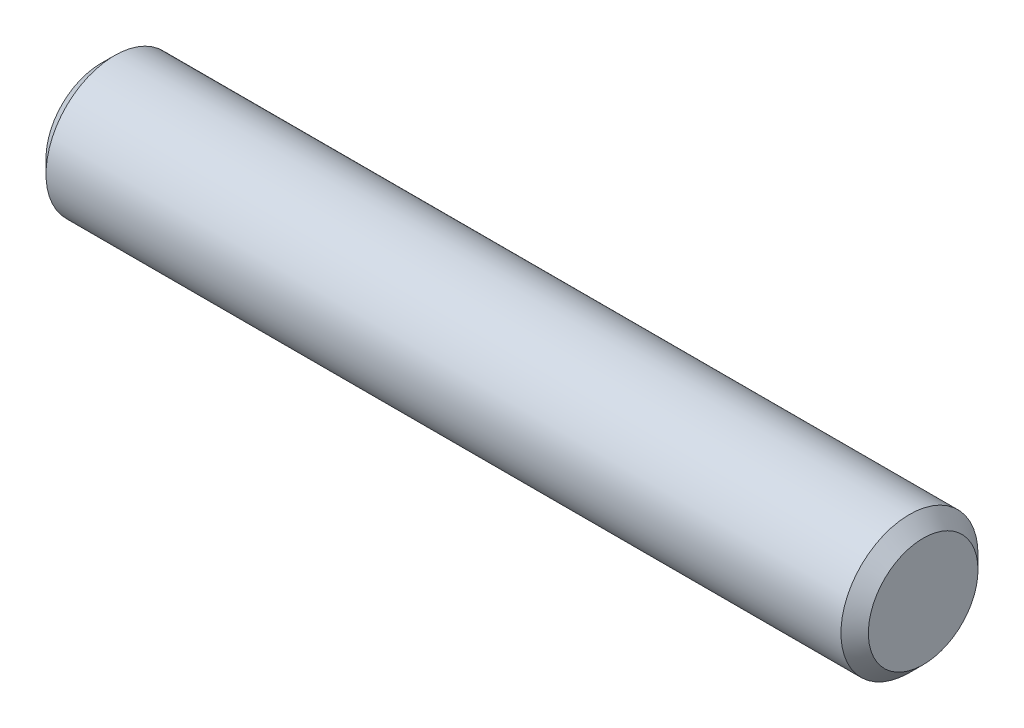
from build123d import *

# Parameters (mm, degrees)
SKETCH2_R           = 1.5875
EXTRUDE1_DEPTH      = 9.525
EXTRUDE1_DEPTH_BACK = 9.525
CHAMFER1_SIZE       = 0.3175


with BuildPart() as part:
    # Sketch2 → Extrude1 (new body, two sides)
    with BuildSketch(Plane(origin=(0, 0, 0), x_dir=(0, 0, -1), z_dir=(1, 0, 0))) as extrude1_sk:
        Circle(SKETCH2_R)
    extrude(amount=EXTRUDE1_DEPTH)
    extrude(extrude1_sk.sketch, amount=-EXTRUDE1_DEPTH_BACK)

    # Chamfer1
    chamfer1_edges = [part.edges().sort_by_distance(p)[0] for p in [
        (-9.525, 0, 1.5875),
        (9.525, 0, 1.5875),
    ]]
    chamfer(chamfer1_edges, length=CHAMFER1_SIZE)


solid = part.part
